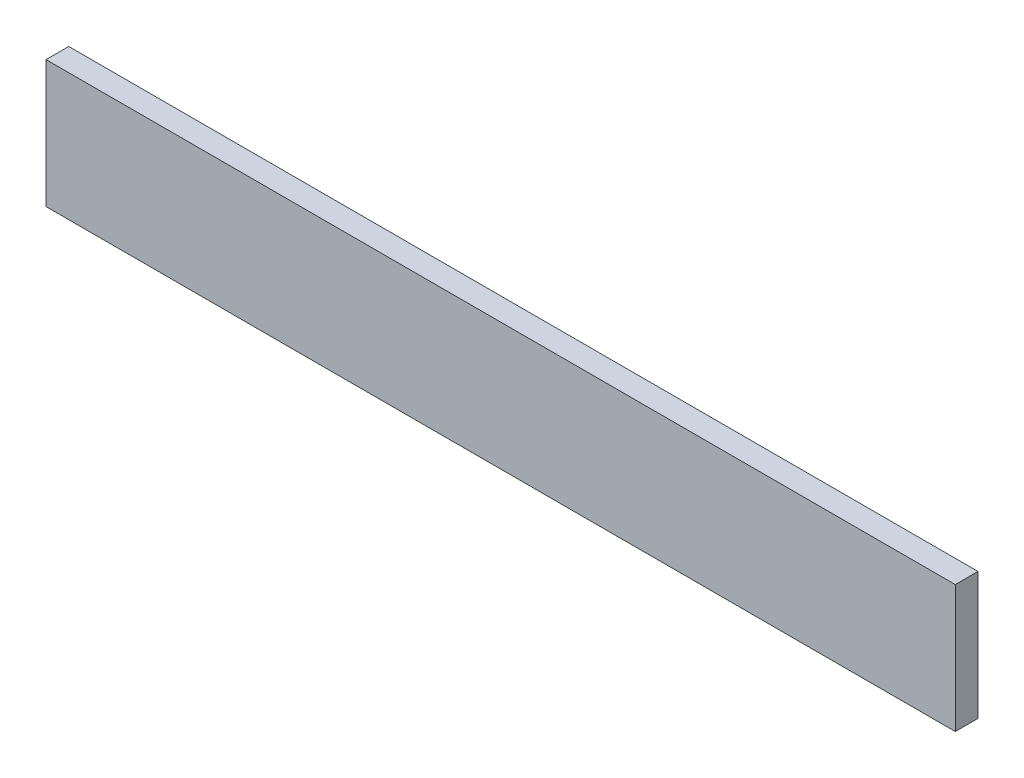
from build123d import *

# Parameters (mm, degrees)
SKETCH1_W           = 127
SKETCH1_H           = 17.78
BOSS_EXTRUDE1_DEPTH = 3.175


with BuildPart() as part:
    # Sketch1 → Boss-Extrude1 (new body)
    with BuildSketch(Plane.XY):
        Rectangle(SKETCH1_W, SKETCH1_H)
    extrude(amount=BOSS_EXTRUDE1_DEPTH)


solid = part.part
